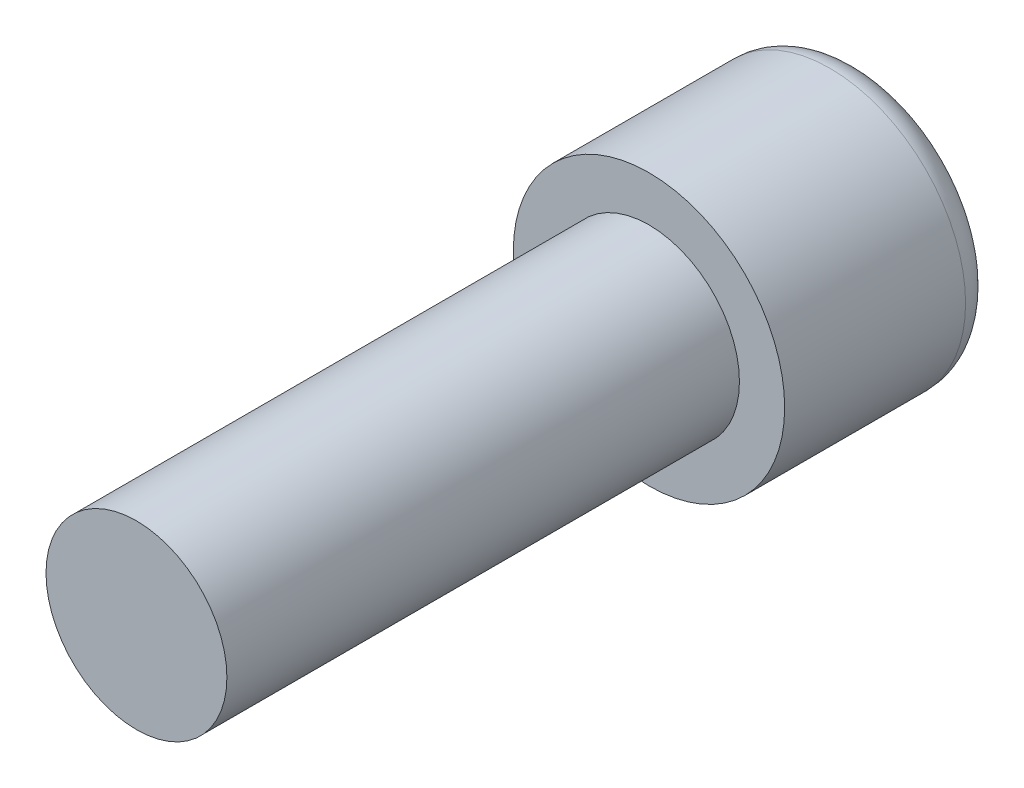
from build123d import *

# Parameters (mm, degrees)
SKETCH1_R           = 0.75
BOSS_EXTRUDE1_DEPTH = 4.25
SKETCH2_R           = 1.125
BOSS_EXTRUDE2_DEPTH = 1.75
FILLET1_R           = 0.25
CUT_EXTRUDE1_DEPTH  = 1


with BuildPart() as part:
    # Sketch1 → Boss-Extrude1 (new body)
    with BuildSketch(Plane.XY):
        Circle(SKETCH1_R)
    extrude(amount=BOSS_EXTRUDE1_DEPTH)

    # Sketch2 → Boss-Extrude2 (add)
    with BuildSketch(Plane(origin=(0, 0, 0), x_dir=(-1, 0, 0), z_dir=(0, 0, -1))):
        Circle(SKETCH2_R)
    extrude(amount=BOSS_EXTRUDE2_DEPTH)

    # Fillet1
    fillet1_edges = [part.edges().sort_by_distance(p)[0] for p in [
        (1.125, 0, -1.75),
    ]]
    fillet(fillet1_edges, radius=FILLET1_R)

    # Sketch3 → Cut-Extrude1 (cut)
    with BuildSketch(Plane(origin=(0, 0, -1.75), x_dir=(-1, 0, 0), z_dir=(0, 0, -1))):
        Polygon((0.229233643, -0.684313722), (0.707249889, -0.143634703), (0.478016246, 0.540679019), (-0.229233643, 0.684313722), (-0.707249889, 0.143634703), (-0.478016246, -0.540679019), align=None)
    extrude(amount=-CUT_EXTRUDE1_DEPTH, mode=Mode.SUBTRACT)


solid = part.part
